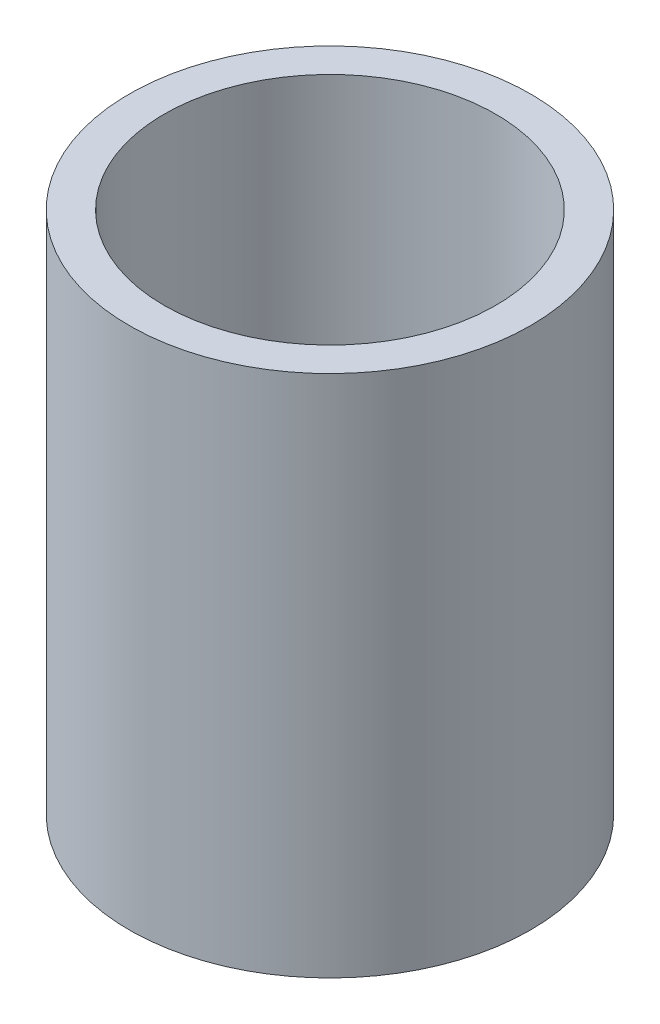
from build123d import *

# Parameters (mm, degrees)
SKETCH_1_R      = 57.5
SKETCH_1_R_2    = 47.5
EXTRUDE_1_DEPTH = 150


with BuildPart() as part:
    # Эскиз1 → Вытянуть-Тонкостенный1 (new body)
    with BuildSketch(Plane(origin=(0, 0, 0), x_dir=(1, 0, 0), z_dir=(0, 1, 0))):
        Circle(SKETCH_1_R)
        Circle(SKETCH_1_R_2, mode=Mode.SUBTRACT)
    extrude(amount=EXTRUDE_1_DEPTH)


solid = part.part
